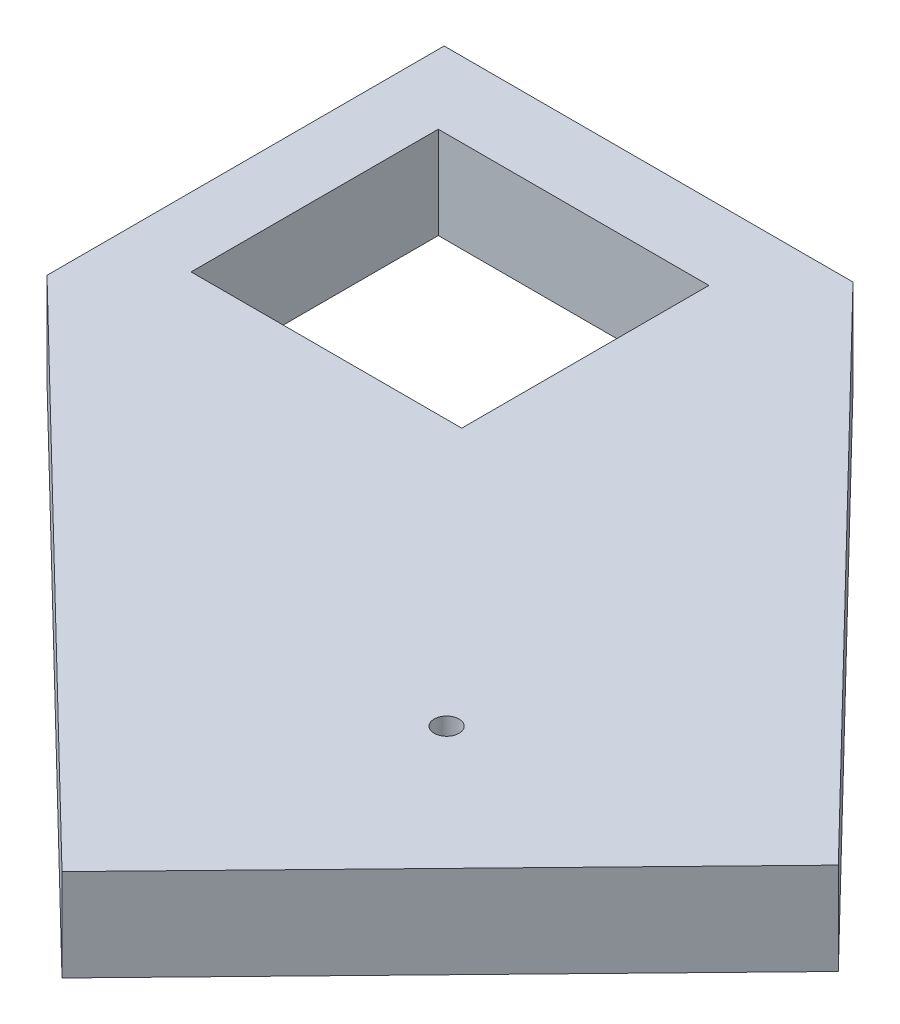
from build123d import *

# Parameters (mm, degrees)
SKETCH1_W           = 58.749440694
SKETCH1_H           = 53.662909032
BOSS_EXTRUDE1_DEPTH = 20
SKETCH2_R           = 2.7
CUT_EXTRUDE1_DEPTH  = 20
SKETCH4_R           = 3


with BuildPart() as part:
    # Sketch1 → Boss-Extrude1 (new body)
    with BuildSketch(Plane(origin=(0, 0, 0), x_dir=(1, 0, 0), z_dir=(0, 1, 0))):
        Polygon((69.363086635, -153.592317311), (152.403813045, -68.102011951), (44.37998875, 43.108355834), (-44.37998875, 43.108355834), (-44.37998875, -43.108355834), align=None)
        Rectangle(SKETCH1_W, SKETCH1_H, mode=Mode.SUBTRACT)
    extrude(amount=BOSS_EXTRUDE1_DEPTH)

    # Sketch2 → Cut-Extrude1 (cut)
    with BuildSketch(Plane(origin=(0, 20, 0), x_dir=(1, 0, 0), z_dir=(0, 1, 0))):
        with Locations((83.759038646, -84.499957196)):
            Circle(SKETCH2_R)
    extrude(amount=-CUT_EXTRUDE1_DEPTH, mode=Mode.SUBTRACT)

    # Cut-Sweep1: sweep along a path in Sketch3
    with BuildLine(Plane.XZ) as cut_sweep1_path:
        CenterArc((83.759038646, 84.499957196), 15, 0, 360)
    # Sketch4 → Cut-Sweep1 (sweep, cut)
    with BuildSketch(Plane(origin=(0, 0, 0), x_dir=(0.703986253, 0, 0.710213599), z_dir=(-0.710213599, 0, 0.703986253))):
        with Locations((103.97823045, 0)):
            Circle(SKETCH4_R)
    sweep(path=cut_sweep1_path.line, mode=Mode.SUBTRACT)


solid = part.part
